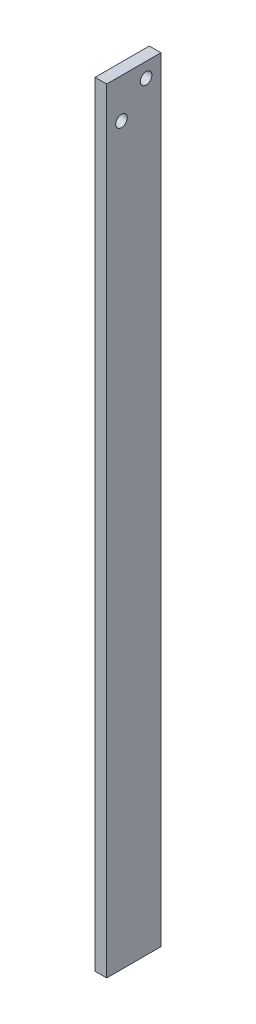
from build123d import *

# Parameters (mm, degrees)
SKETCH_1_W      = 14
SKETCH_1_H      = 200
SKETCH_1_R      = 1.5
EXTRUDE_1_DEPTH = 3


with BuildPart() as part:
    # 草图1 → 凸台-拉伸1 (new body)
    with BuildSketch(Plane(origin=(0, 0, 0), x_dir=(0, 0, -1), z_dir=(1, 0, 0))):
        with Locations((7, -100)):
            Rectangle(SKETCH_1_W, SKETCH_1_H)
        with Locations((10.181980515, -3.818019485)):
            Circle(SKETCH_1_R, mode=Mode.SUBTRACT)
        with Locations((3.818019485, -10.181980515)):
            Circle(SKETCH_1_R, mode=Mode.SUBTRACT)
    extrude(amount=EXTRUDE_1_DEPTH)


solid = part.part
